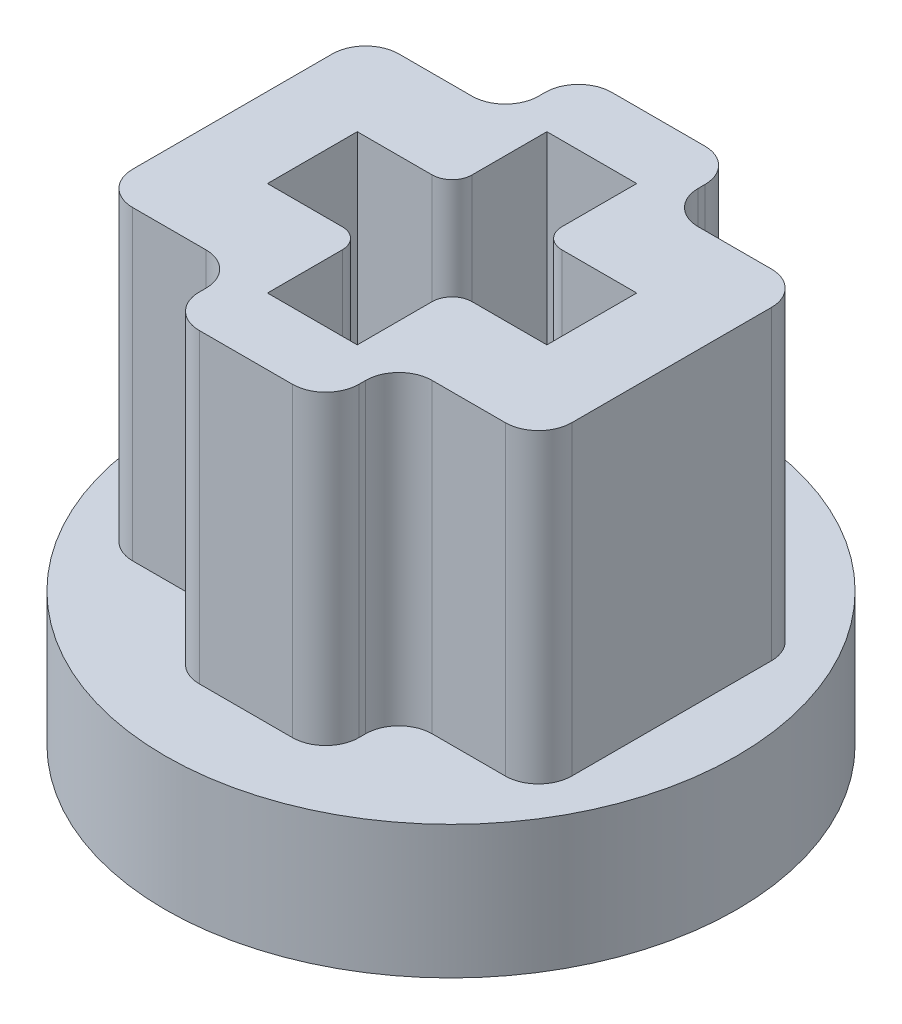
from build123d import *

# Parameters (mm, degrees)
BUTTON_TOP_DEPTH        = 1.8
BUTTON_WALLS_DEPTH      = 4.8
OFFSET_2_DEPTH          = 0.2
STEM_START              = 0.2
STEM_HOUSING_DEPTH      = 4.6
SPOKES_DEPTH            = 0.2
CHAMFER1_SIZE           = 1.5
SKETCH11_R              = 47.776797093
SKETCH11_R_2            = 4.295081168
CUT_EXTRUDE1_DEPTH      = 10
CUT_EXTRUDE1_DEPTH_BACK = 10


with BuildPart() as part:
    # Sketch1 → button top (new body)
    with BuildSketch(Plane(origin=(0, 0, 0), x_dir=(1, 0, 0), z_dir=(0, 1, 0))):
        with BuildLine():
            Line((17, -12), (-17, -12))
            ThreePointArc((-17, -12), (-29, 0), (-17, 12))
            Line((-17, 12), (17, 12))
            ThreePointArc((17, 12), (29, 0), (17, -12))
        make_face()
    extrude(amount=BUTTON_TOP_DEPTH)

    # Sketch2 → button walls (add)
    with BuildSketch(Plane(origin=(0, 1.8, 0), x_dir=(1, 0, 0), z_dir=(0, 1, 0))):
        with BuildLine():
            Line((-17, 12), (17, 12))
            ThreePointArc((17, 12), (29, 0), (17, -12))
            Line((17, -12), (-17, -12))
            ThreePointArc((-17, -12), (-29, 0), (-17, 12))
        make_face()
        with BuildLine():
            Line((-17, 10.2), (17, 10.2))
            ThreePointArc((17, 10.2), (27.2, 0), (17, -10.2))
            Line((17, -10.2), (-17, -10.2))
            ThreePointArc((-17, -10.2), (-27.2, 0), (-17, 10.2))
        make_face(mode=Mode.SUBTRACT)
    extrude(amount=BUTTON_WALLS_DEPTH)

    # Sketch5 → offset 2 (add)
    with BuildSketch(Plane(origin=(0, 1.8, 0), x_dir=(1, 0, 0), z_dir=(0, 1, 0))):
        with BuildLine():
            Line((-12, 5), (12, 5))
            ThreePointArc((12, 5), (17, 0), (12, -5))
            Line((12, -5), (-12, -5))
            ThreePointArc((-12, -5), (-17, 0), (-12, 5))
        make_face()
    extrude(amount=OFFSET_2_DEPTH)

    # Sketch3 → stem housing (add)
    with BuildSketch(Plane(origin=(0, 1.8, 0), x_dir=(1, 0, 0), z_dir=(0, 1, 0)).offset(STEM_START)):
        with BuildLine():
            Line((-3.6, 2.6), (-3.6, -2.6))
            Line((-3.6, -2.6), (-1.496662955, -2.6))
            ThreePointArc((-1.496662955, -2.6), (0, -3), (1.496662955, -2.6))
            Line((1.496662955, -2.6), (3.6, -2.6))
            Line((3.6, -2.6), (3.6, 2.6))
            Line((3.6, 2.6), (1.496662955, 2.6))
            ThreePointArc((1.496662955, 2.6), (0, 3), (-1.496662955, 2.6))
            Line((-1.496662955, 2.6), (-3.6, 2.6))
        make_face()
        with BuildLine():
            Line((-0.675, 0.975), (-0.675, 2.1))
            Line((-0.675, 2.1), (0.675, 2.1))
            Line((0.675, 2.1), (0.675, 0.975))
            ThreePointArc((0.675, 0.975), (0.762867966, 0.762867966), (0.975, 0.675))
            Line((0.975, 0.675), (2.1, 0.675))
            Line((2.1, 0.675), (2.1, -0.675))
            Line((2.1, -0.675), (0.975, -0.675))
            ThreePointArc((0.975, -0.675), (0.762867966, -0.762867966), (0.675, -0.975))
            Line((0.675, -0.975), (0.675, -2.1))
            Line((0.675, -2.1), (-0.675, -2.1))
            Line((-0.675, -2.1), (-0.675, -0.975))
            ThreePointArc((-0.675, -0.975), (-0.762867966, -0.762867966), (-0.975, -0.675))
            Line((-0.975, -0.675), (-2.1, -0.675))
            Line((-2.1, -0.675), (-2.1, 0.675))
            Line((-2.1, 0.675), (-0.975, 0.675))
            ThreePointArc((-0.975, 0.675), (-0.762867966, 0.762867966), (-0.675, 0.975))
        make_face(mode=Mode.SUBTRACT)
        with BuildLine():
            ThreePointArc((14.738, -2), (15.091553391, -1.853553391), (15.238, -1.5))
            Line((15.238, -1.5), (15.238, 1.5))
            ThreePointArc((15.238, 1.5), (15.091553391, 1.853553391), (14.738, 2))
            Line((14.738, 2), (13.638, 2))
            ThreePointArc((13.638, 2), (13.284446609, 2.146446609), (13.138, 2.5))
            Line((13.138, 2.5), (13.138, 2.6))
            ThreePointArc((13.138, 2.6), (12.991553391, 2.953553391), (12.638, 3.1))
            Line((12.638, 3.1), (11.238, 3.1))
            ThreePointArc((11.238, 3.1), (10.884446609, 2.953553391), (10.738, 2.6))
            Line((10.738, 2.6), (10.738, 2.5))
            ThreePointArc((10.738, 2.5), (10.591553391, 2.146446609), (10.238, 2))
            Line((10.238, 2), (9.138, 2))
            ThreePointArc((9.138, 2), (8.784446609, 1.853553391), (8.638, 1.5))
            Line((8.638, 1.5), (8.638, -1.5))
            ThreePointArc((8.638, -1.5), (8.784446609, -1.853553391), (9.138, -2))
            Line((9.138, -2), (10.238, -2))
            ThreePointArc((10.238, -2), (10.591553391, -2.146446609), (10.738, -2.5))
            Line((10.738, -2.5), (10.738, -2.6))
            ThreePointArc((10.738, -2.6), (10.884446609, -2.953553391), (11.238, -3.1))
            Line((11.238, -3.1), (12.638, -3.1))
            ThreePointArc((12.638, -3.1), (12.991553391, -2.953553391), (13.138, -2.6))
            Line((13.138, -2.6), (13.138, -2.5))
            ThreePointArc((13.138, -2.5), (13.284446609, -2.146446609), (13.638, -2))
            Line((13.638, -2), (14.738, -2))
        make_face()
        with BuildLine():
            Line((14.038, 0.675), (14.038, -0.675))
            Line((14.038, -0.675), (12.913, -0.675))
            ThreePointArc((12.913, -0.675), (12.700867966, -0.762867966), (12.613, -0.975))
            Line((12.613, -0.975), (12.613, -2.1))
            Line((12.613, -2.1), (11.263, -2.1))
            Line((11.263, -2.1), (11.263, -0.975))
            ThreePointArc((11.263, -0.975), (11.175132034, -0.762867966), (10.963, -0.675))
            Line((10.963, -0.675), (9.838, -0.675))
            Line((9.838, -0.675), (9.838, 0.675))
            Line((9.838, 0.675), (10.963, 0.675))
            ThreePointArc((10.963, 0.675), (11.175132034, 0.762867966), (11.263, 0.975))
            Line((11.263, 0.975), (11.263, 2.1))
            Line((11.263, 2.1), (12.613, 2.1))
            Line((12.613, 2.1), (12.613, 0.975))
            ThreePointArc((12.613, 0.975), (12.700867966, 0.762867966), (12.913, 0.675))
            Line((12.913, 0.675), (14.038, 0.675))
        make_face(mode=Mode.SUBTRACT)
        with BuildLine():
            Line((-13.138, 2.6), (-13.138, 2.5))
            ThreePointArc((-13.138, 2.5), (-13.284446609, 2.146446609), (-13.638, 2))
            Line((-13.638, 2), (-14.738, 2))
            ThreePointArc((-14.738, 2), (-15.091553391, 1.853553391), (-15.238, 1.5))
            Line((-15.238, 1.5), (-15.238, -1.5))
            ThreePointArc((-15.238, -1.5), (-15.091553391, -1.853553391), (-14.738, -2))
            Line((-14.738, -2), (-13.638, -2))
            ThreePointArc((-13.638, -2), (-13.284446609, -2.146446609), (-13.138, -2.5))
            Line((-13.138, -2.5), (-13.138, -2.6))
            ThreePointArc((-13.138, -2.6), (-12.991553391, -2.953553391), (-12.638, -3.1))
            Line((-12.638, -3.1), (-11.238, -3.1))
            ThreePointArc((-11.238, -3.1), (-10.884446609, -2.953553391), (-10.738, -2.6))
            Line((-10.738, -2.6), (-10.738, -2.5))
            ThreePointArc((-10.738, -2.5), (-10.591553391, -2.146446609), (-10.238, -2))
            Line((-10.238, -2), (-9.138, -2))
            ThreePointArc((-9.138, -2), (-8.784446609, -1.853553391), (-8.638, -1.5))
            Line((-8.638, -1.5), (-8.638, 1.5))
            ThreePointArc((-8.638, 1.5), (-8.784446609, 1.853553391), (-9.138, 2))
            Line((-9.138, 2), (-10.238, 2))
            ThreePointArc((-10.238, 2), (-10.591553391, 2.146446609), (-10.738, 2.5))
            Line((-10.738, 2.5), (-10.738, 2.6))
            ThreePointArc((-10.738, 2.6), (-10.884446609, 2.953553391), (-11.238, 3.1))
            Line((-11.238, 3.1), (-12.638, 3.1))
            ThreePointArc((-12.638, 3.1), (-12.991553391, 2.953553391), (-13.138, 2.6))
        make_face()
        with BuildLine():
            ThreePointArc((-12.913, 0.675), (-12.700867966, 0.762867966), (-12.613, 0.975))
            Line((-12.613, 0.975), (-12.613, 2.1))
            Line((-12.613, 2.1), (-11.263, 2.1))
            Line((-11.263, 2.1), (-11.263, 0.975))
            ThreePointArc((-11.263, 0.975), (-11.175132034, 0.762867966), (-10.963, 0.675))
            Line((-10.963, 0.675), (-9.838, 0.675))
            Line((-9.838, 0.675), (-9.838, -0.675))
            Line((-9.838, -0.675), (-10.963, -0.675))
            ThreePointArc((-10.963, -0.675), (-11.175132034, -0.762867966), (-11.263, -0.975))
            Line((-11.263, -0.975), (-11.263, -2.1))
            Line((-11.263, -2.1), (-12.613, -2.1))
            Line((-12.613, -2.1), (-12.613, -0.975))
            ThreePointArc((-12.613, -0.975), (-12.700867966, -0.762867966), (-12.913, -0.675))
            Line((-12.913, -0.675), (-14.038, -0.675))
            Line((-14.038, -0.675), (-14.038, 0.675))
            Line((-14.038, 0.675), (-12.913, 0.675))
        make_face(mode=Mode.SUBTRACT)
    extrude(amount=STEM_HOUSING_DEPTH)

    # Sketch4 → spokes (add)
    with BuildSketch(Plane(origin=(0, 1.8, 0), x_dir=(1, 0, 0), z_dir=(0, 1, 0))):
        with BuildLine():
            Line((-0.8, 3), (-0.8, 10.2))
            ThreePointArc((-0.8, 10.2), (0, 11), (0.8, 10.2))
            Line((0.8, 10.2), (0.8, 3))
            ThreePointArc((0.8, 3), (0, 2.2), (-0.8, 3))
        make_face()
        with BuildLine():
            Line((17, -0.8), (27.2, -0.8))
            ThreePointArc((27.2, -0.8), (28, 0), (27.2, 0.8))
            Line((27.2, 0.8), (17, 0.8))
            ThreePointArc((17, 0.8), (16.2, 0), (17, -0.8))
        make_face()
        with BuildLine():
            Line((11.2, 3.1), (11.2, 10.2))
            ThreePointArc((11.2, 10.2), (12, 11), (12.8, 10.2))
            Line((12.8, 10.2), (12.8, 3.1))
            ThreePointArc((12.8, 3.1), (12, 2.3), (11.2, 3.1))
        make_face()
        with BuildLine():
            Line((-12.8, 3.1), (-12.8, 10.2))
            ThreePointArc((-12.8, 10.2), (-12, 11), (-11.2, 10.2))
            Line((-11.2, 10.2), (-11.2, 3.1))
            ThreePointArc((-11.2, 3.1), (-12, 2.3), (-12.8, 3.1))
        make_face()
        with BuildLine():
            Line((-17, -0.8), (-27.2, -0.8))
            ThreePointArc((-27.2, -0.8), (-28, 0), (-27.2, 0.8))
            Line((-27.2, 0.8), (-17, 0.8))
            ThreePointArc((-17, 0.8), (-16.2, 0), (-17, -0.8))
        make_face()
        with BuildLine():
            Line((-0.8, -3), (-0.8, -10.2))
            ThreePointArc((-0.8, -10.2), (0, -11), (0.8, -10.2))
            Line((0.8, -10.2), (0.8, -3))
            ThreePointArc((0.8, -3), (0, -2.2), (-0.8, -3))
        make_face()
        with BuildLine():
            Line((11.2, -3.1), (11.2, -10.2))
            ThreePointArc((11.2, -10.2), (12, -11), (12.8, -10.2))
            Line((12.8, -10.2), (12.8, -3.1))
            ThreePointArc((12.8, -3.1), (12, -2.3), (11.2, -3.1))
        make_face()
        with BuildLine():
            Line((-12.8, -3.1), (-12.8, -10.2))
            ThreePointArc((-12.8, -10.2), (-12, -11), (-11.2, -10.2))
            Line((-11.2, -10.2), (-11.2, -3.1))
            ThreePointArc((-11.2, -3.1), (-12, -2.3), (-12.8, -3.1))
        make_face()
    extrude(amount=SPOKES_DEPTH)

    # Chamfer1
    chamfer1_edges = [part.edges().sort_by_distance(p)[0] for p in [
        (-27.2, 6.6, 0),
        (0, 6.6, 10.2),
        (27.2, 6.6, 0),
        (0, 6.6, -10.2),
    ]]
    chamfer(chamfer1_edges, length=CHAMFER1_SIZE)

    # Cut-Sweep1: sweep along a path in Sketch10
    with BuildLine(Plane.XZ) as cut_sweep1_path:
        Line((-17, 12), (17, 12))
        ThreePointArc((17, 12), (29, 0), (17, -12))
        Line((17, -12), (-17, -12))
        ThreePointArc((-17, -12), (-29, 0), (-17, 12))
    # Sketch6 → Cut-Sweep1 (sweep, cut)
    with BuildSketch(Plane.XY):
        with BuildLine():
            Line((-28.261522369, 0), (-28.461522369, 0.2))
            ThreePointArc((-28.461522369, 0.2), (-28.860054223, 0.79644507), (-29, 1.5))
            Line((-29, 1.5), (-29, 0))
            Line((-29, 0), (-28.261522369, 0))
        make_face()
    sweep(path=cut_sweep1_path.line, mode=Mode.SUBTRACT)

    # Sketch11 → Cut-Extrude1 (cut, two sides)
    with BuildSketch(Plane(origin=(0, 2, 0), x_dir=(1, 0, 0), z_dir=(0, 1, 0))) as cut_extrude1_sk:
        with Locations((-11.954336916, 0)):
            Circle(SKETCH11_R)
        with Locations(Location((-11.954336916, 0, 0), (0, 0, 270))):
            Circle(SKETCH11_R_2, mode=Mode.SUBTRACT)
    extrude(amount=CUT_EXTRUDE1_DEPTH, mode=Mode.SUBTRACT)
    extrude(cut_extrude1_sk.sketch, amount=-CUT_EXTRUDE1_DEPTH_BACK, mode=Mode.SUBTRACT)


solid = part.part
